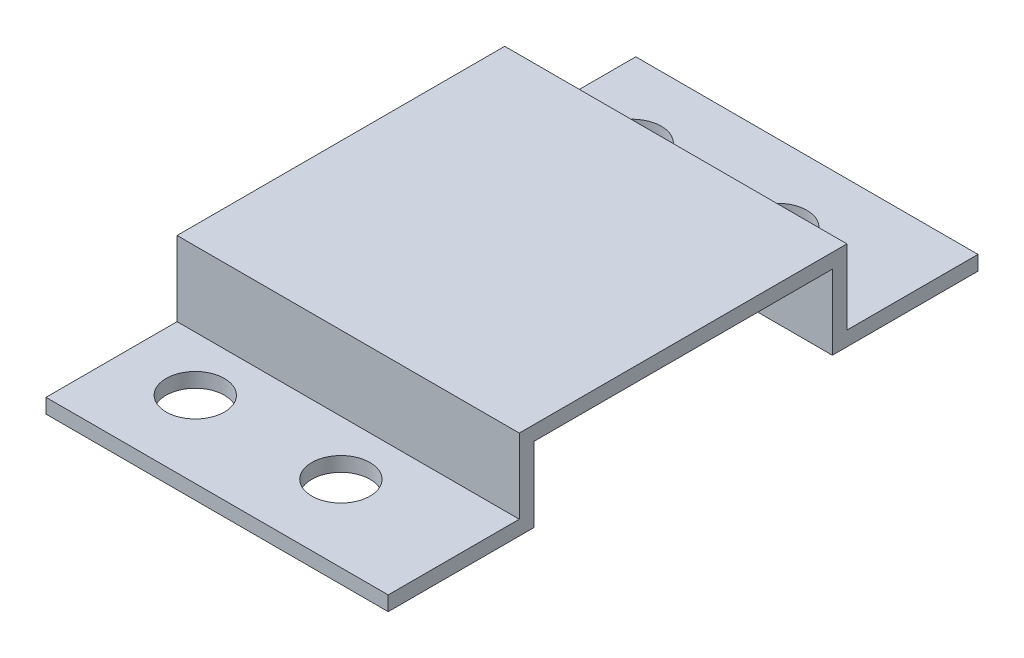
from build123d import *

# Parameters (mm, degrees)
EXTRUDE_1_DEPTH     = 47
SKETCH_2_R          = 4
CUT_EXTRUDE_1_DEPTH = 10


with BuildPart() as part:
    # Эскиз1 → Вытянуть-Тонкостенный1 (new body)
    with BuildSketch(Plane(origin=(0, 0, 0), x_dir=(0, 0, -1), z_dir=(1, 0, 0))):
        Polygon((-40.5, 0), (-20.5, 0), (-20.5, 10.25), (20.5, 10.25), (20.5, 0), (40.5, 0), (40.5, 2), (22.5, 2), (22.5, 12.25), (-22.5, 12.25), (-22.5, 2), (-40.5, 2), align=None)
    extrude(amount=EXTRUDE_1_DEPTH)

    # Эскиз2 → Вырез-Вытянуть1 (cut)
    with BuildSketch(Plane.XZ):
        with Locations((10, 30)):
            Circle(SKETCH_2_R)
        with Locations((30, 30)):
            Circle(SKETCH_2_R)
        with Locations((30, -30)):
            Circle(SKETCH_2_R)
        with Locations((10, -30)):
            Circle(SKETCH_2_R)
    extrude(amount=-CUT_EXTRUDE_1_DEPTH, mode=Mode.SUBTRACT)


solid = part.part
